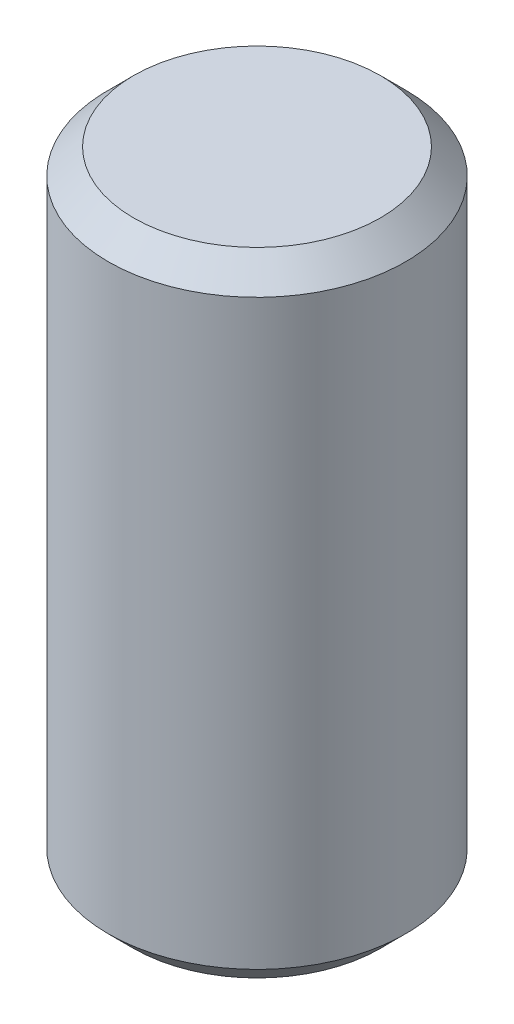
from build123d import *

# Parameters (mm, degrees)
SKETCH1_W     = 2.9845
SKETCH1_H     = 12.7
CHAMFER1_SIZE = 0.508


with BuildPart() as part:
    # Sketch1 → Revolve1 (revolve)
    with BuildSketch(Plane.XY):
        with Locations((1.49225, 0)):
            Rectangle(SKETCH1_W, SKETCH1_H)
    revolve(axis=Axis((0, 6.080207887, 0), (0, -1, 0)))

    # Chamfer1
    chamfer1_edges = [part.edges().sort_by_distance(p)[0] for p in [
        (-2.9845, 6.35, 0),
        (-2.9845, -6.35, 0),
    ]]
    chamfer(chamfer1_edges, length=CHAMFER1_SIZE)


solid = part.part
